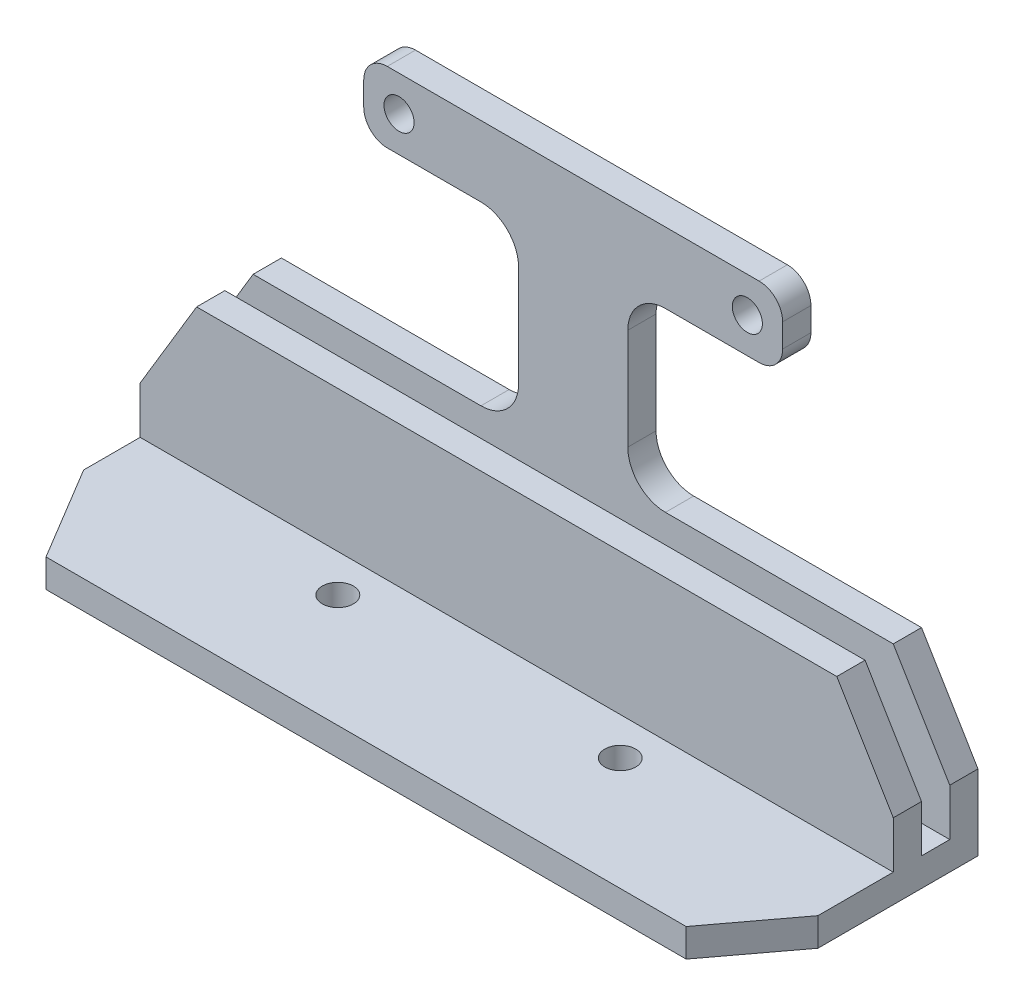
from build123d import *

# Parameters (mm, degrees)
BOSS_EXTRUDE1_DEPTH = 3
SKETCH3_R           = 1.6
BOSS_EXTRUDE2_DEPTH = 3
SKETCH2_W           = 80
SKETCH2_H           = 3
BOSS_EXTRUDE3_DEPTH = 3
SKETCH8_W           = 80
SKETCH8_H           = 3
BOSS_EXTRUDE6_DEPTH = 16
SKETCH21_R          = 1.65
CUT_EXTRUDE1_DEPTH  = 4
CUT_EXTRUDE2_DEPTH  = 4


with BuildPart() as part:
    # Sketch1 → Boss-Extrude1 (new body)
    with BuildSketch(Plane.XY):
        Polygon((40, -2.5), (34, 7.5), (-34, 7.5), (-40, -2.5), (-40, -7.5), (40, -7.5), align=None)
    extrude(amount=BOSS_EXTRUDE1_DEPTH)



with BuildPart() as body_2:
    # Sketch3 → Boss-Extrude2 (new body)
    with BuildSketch(Plane(origin=(0, 0, -3), x_dir=(-1, 0, 0), z_dir=(0, 0, -1))):
        with BuildLine():
            Line((40, -7.5), (-40, -7.5))
            Line((-40, -7.5), (-40, -2.5))
            Line((-40, -2.5), (-34, 7.5))
            Line((-34, 7.5), (-9.8, 7.5))
            ThreePointArc((-9.8, 7.5), (-6.971572875, 8.671572875), (-5.8, 11.5))
            Line((-5.8, 11.5), (-5.8, 22.25))
            ThreePointArc((-5.8, 22.25), (-6.971572875, 25.078427125), (-9.8, 26.25))
            Line((-9.8, 26.25), (-19.75, 26.25))
            ThreePointArc((-19.75, 26.25), (-21.517766953, 26.982233047), (-22.25, 28.75))
            Line((-22.25, 28.75), (-22.25, 31.25))
            ThreePointArc((-22.25, 31.25), (-21.517766953, 33.017766953), (-19.75, 33.75))
            Line((-19.75, 33.75), (19.75, 33.75))
            ThreePointArc((19.75, 33.75), (21.517766953, 33.017766953), (22.25, 31.25))
            Line((22.25, 31.25), (22.25, 28.75))
            ThreePointArc((22.25, 28.75), (21.517766953, 26.982233047), (19.75, 26.25))
            Line((19.75, 26.25), (9.8, 26.25))
            ThreePointArc((9.8, 26.25), (6.971572875, 25.078427125), (5.8, 22.25))
            Line((5.8, 22.25), (5.8, 11.5))
            ThreePointArc((5.8, 11.5), (6.971572875, 8.671572875), (9.8, 7.5))
            Line((9.8, 7.5), (34, 7.5))
            Line((34, 7.5), (40, -2.5))
            Line((40, -2.5), (40, -7.5))
        make_face()
        with Locations((-18.5, 30)):
            Circle(SKETCH3_R, mode=Mode.SUBTRACT)
        with Locations((18.5, 30)):
            Circle(SKETCH3_R, mode=Mode.SUBTRACT)
    extrude(amount=BOSS_EXTRUDE2_DEPTH)


with BuildPart() as part_1:
    add(part.part)

    add(body_2.part)  # Boss-Extrude3 merges body 2
    # Sketch2 → Boss-Extrude3 (add)
    with BuildSketch(Plane(origin=(0, -7.5, 0), x_dir=(1, 0, 0), z_dir=(0, 1, 0))):
        with Locations((0, 4.5)):
            Rectangle(SKETCH2_W, SKETCH2_H)
        with Locations((0, 1.5)):
            Rectangle(SKETCH2_W, SKETCH2_H)
        with Locations((0, -1.5)):
            Rectangle(SKETCH2_W, SKETCH2_H)
    extrude(amount=-BOSS_EXTRUDE3_DEPTH)

    # Sketch8 → Boss-Extrude6 (add)
    with BuildSketch(Plane.XY.offset(3)):
        with Locations((0, -9)):
            Rectangle(SKETCH8_W, SKETCH8_H)
    extrude(amount=BOSS_EXTRUDE6_DEPTH)

    # Sketch21 → Cut-Extrude1 (cut, through all)
    with BuildSketch(Plane(origin=(0, -7.5, 0), x_dir=(1, 0, 0), z_dir=(0, 1, 0))):
        with Locations((-15, -7)):
            Circle(SKETCH21_R)
        with Locations((15, -7)):
            Circle(SKETCH21_R)
    extrude(amount=-CUT_EXTRUDE1_DEPTH, mode=Mode.SUBTRACT)

    # Sketch24 → Cut-Extrude2 (cut, through all)
    with BuildSketch(Plane(origin=(0, -7.5, 0), x_dir=(1, 0, 0), z_dir=(0, 1, 0))):
        Polygon((-40, -19), (-40, -9), (-34, -19), align=None)
        Polygon((40, -19), (34, -19), (40, -11), align=None)
    extrude(amount=-CUT_EXTRUDE2_DEPTH, mode=Mode.SUBTRACT)


solid = part_1.part
